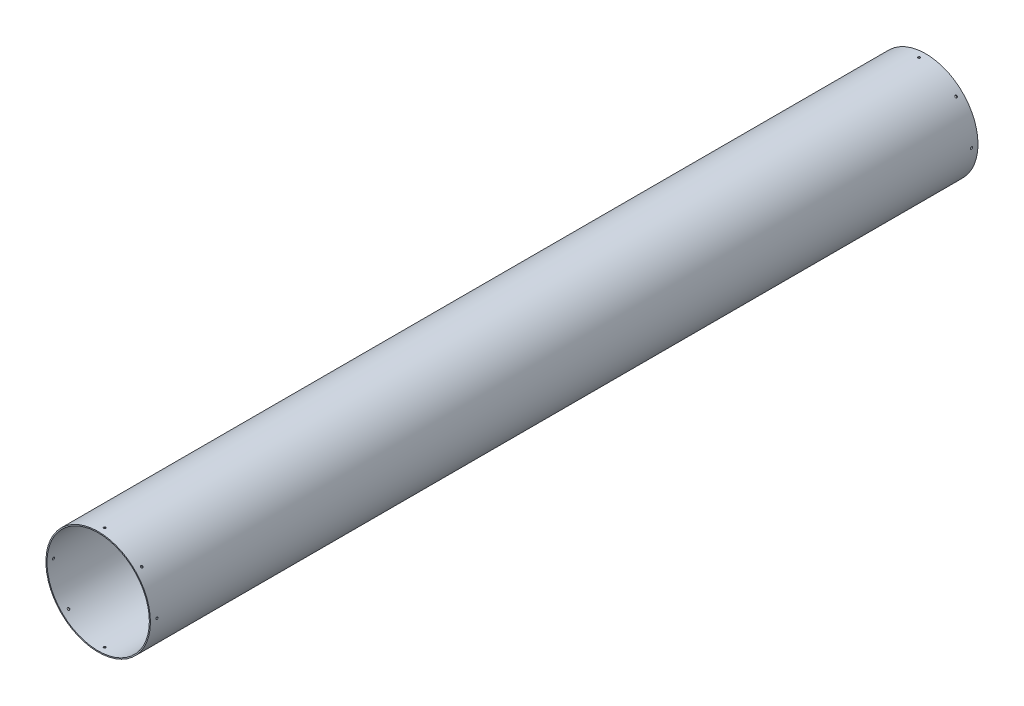
from build123d import *

# Parameters (mm, degrees)
SKETCH1_R           = 152.4
BOSS_EXTRUDE1_DEPTH = 2413
SKETCH2_R           = 149.225
CUT_EXTRUDE1_DEPTH  = 2413
SKETCH3_R           = 3.175
CUT_EXTRUDE2_DEPTH  = 190.5
CIRPATTERN3_COUNT   = 8
SKETCH4_R           = 3.175
CUT_EXTRUDE4_DEPTH  = 270.764
CIRPATTERN5_COUNT   = 8


with BuildPart() as part:
    # Sketch1 → Boss-Extrude1 (new body)
    with BuildSketch(Plane.XY):
        Circle(SKETCH1_R)
    extrude(amount=BOSS_EXTRUDE1_DEPTH)

    # Sketch2 → Cut-Extrude1 (cut)
    with BuildSketch(Plane.XY.offset(2413)):
        Circle(SKETCH2_R)
    extrude(amount=-CUT_EXTRUDE1_DEPTH, mode=Mode.SUBTRACT)

    # Sketch3 → Cut-Extrude2 (cut)
    with BuildSketch(Plane(origin=(0, 0, 0), x_dir=(1, 0, 0), z_dir=(0, 1, 0))):
        with Locations((0, -19.05)):
            Circle(SKETCH3_R)
    cut_extrude2 = extrude(amount=CUT_EXTRUDE2_DEPTH, mode=Mode.SUBTRACT)

    # CirPattern3: Cut-Extrude2 ×8 about axis
    cirpattern3_axis = Axis((0, 0, 0), (0, 0, 1))
    for i in range(1, CIRPATTERN3_COUNT):
        add(cut_extrude2.rotate(cirpattern3_axis, i * 360 / CIRPATTERN3_COUNT), mode=Mode.SUBTRACT)

    # Sketch4 → Cut-Extrude4 (cut)
    with BuildSketch(Plane(origin=(0, 0, 0), x_dir=(1, 0, 0), z_dir=(0, 1, 0))):
        with Locations((0, -2393.95)):
            Circle(SKETCH4_R)
    cut_extrude4 = extrude(amount=-CUT_EXTRUDE4_DEPTH, mode=Mode.SUBTRACT)

    # CirPattern5: Cut-Extrude4 ×8 about axis
    cirpattern5_axis = Axis((0, 0, 2413), (0, 0, 1))
    for i in range(1, CIRPATTERN5_COUNT):
        add(cut_extrude4.rotate(cirpattern5_axis, i * 360 / CIRPATTERN5_COUNT), mode=Mode.SUBTRACT)


solid = part.part
